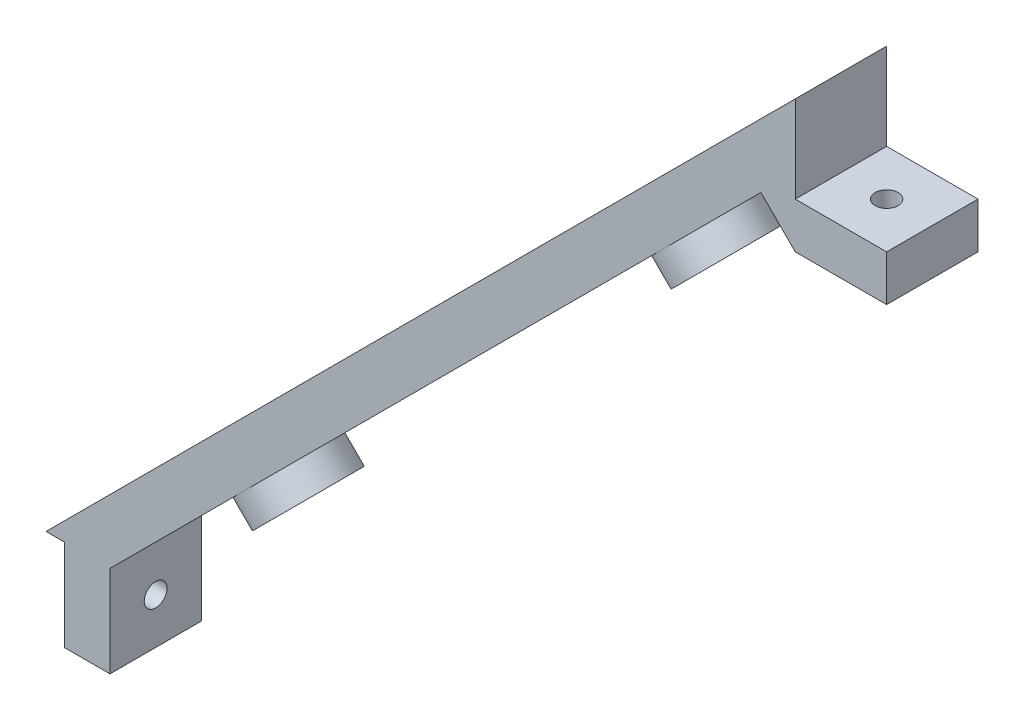
from build123d import *

# Parameters (mm, degrees)
MAIN_DEPTH         = 5
SKETCH2_R          = 1.25
FIXHOLE1_DEPTH     = 83
SKETCH3_R          = 1.25
FIXHOLE2_DEPTH     = 83.5
SKETCH7_R          = 5
BOARDSUPPORT_DEPTH = 3
SKETCH8_R          = 1.25
HOLEFIX_DEPTH      = 66.932503526
SKETCH6_R          = 1.25
CUT_EXTRUDE2_DEPTH = 63.932503526
LPATTERN1_COUNT    = 5
LPATTERN1_PITCH    = 20


with BuildPart() as part:
    # Sketch1 → Main (new body, symmetric)
    with BuildSketch(Plane.XY):
        Polygon((-41, -41), (41, 41), (41, 31.5), (51, 31.5), (51, 26.5), (41, 26.5), (37.25, 30.25), (-34, -41), (-34, -51), (-39, -51), (-39, -41), align=None)
    extrude(amount=MAIN_DEPTH, both=True)

    # Sketch2 → FixHole1 (cut, through all)
    with BuildSketch(Plane(origin=(41, 0, 0), x_dir=(0, 0, -1), z_dir=(1, 0, 0))):
        with Locations((0, -46)):
            Circle(SKETCH2_R)
    extrude(amount=-FIXHOLE1_DEPTH, mode=Mode.SUBTRACT)

    # Sketch3 → FixHole2 (cut, through all)
    with BuildSketch(Plane(origin=(0, 31.5, 0), x_dir=(-1, 0, 0), z_dir=(0, -1, 0))):
        with Locations((-46, 0)):
            Circle(SKETCH3_R)
    extrude(amount=FIXHOLE2_DEPTH, mode=Mode.SUBTRACT)

    # Sketch7 → BoardSupport (add)
    with BuildSketch(Plane(origin=(3.5, -3.5, 0), x_dir=(0, 0, 1), z_dir=(-0.707106781, 0.707106781, 0))):
        with Locations((0, -32.4)):
            Circle(SKETCH7_R)
        with Locations((0, 32.4)):
            Circle(SKETCH7_R)
    extrude(amount=-BOARDSUPPORT_DEPTH)

    # Sketch8 → HoleFix (cut, through all)
    with BuildSketch(Plane(origin=(5.621320344, -5.621320344, 0), x_dir=(0, 0, -1), z_dir=(0.707106781, -0.707106781, 0))):
        with Locations((0, 32.4)):
            Circle(SKETCH8_R)
        with Locations((0, -32.4)):
            Circle(SKETCH8_R)
    extrude(amount=-HOLEFIX_DEPTH, mode=Mode.SUBTRACT)

    # Sketch6 → Cut-Extrude2 (cut, through all)
    with BuildSketch(Plane(origin=(3.5, -3.5, 0), x_dir=(0, 0, 1), z_dir=(-0.707106781, 0.707106781, 0))):
        with Locations((0, 40)):
            Circle(SKETCH6_R)
    cut_extrude2 = extrude(amount=CUT_EXTRUDE2_DEPTH, mode=Mode.SUBTRACT)

    # LPattern1: Cut-Extrude2 ×5
    with Locations(*[Vector(-0.707106781, -0.707106781, 0) * (i * LPATTERN1_PITCH) for i in range(1, LPATTERN1_COUNT)]):
        add(cut_extrude2, mode=Mode.SUBTRACT)


solid = part.part
